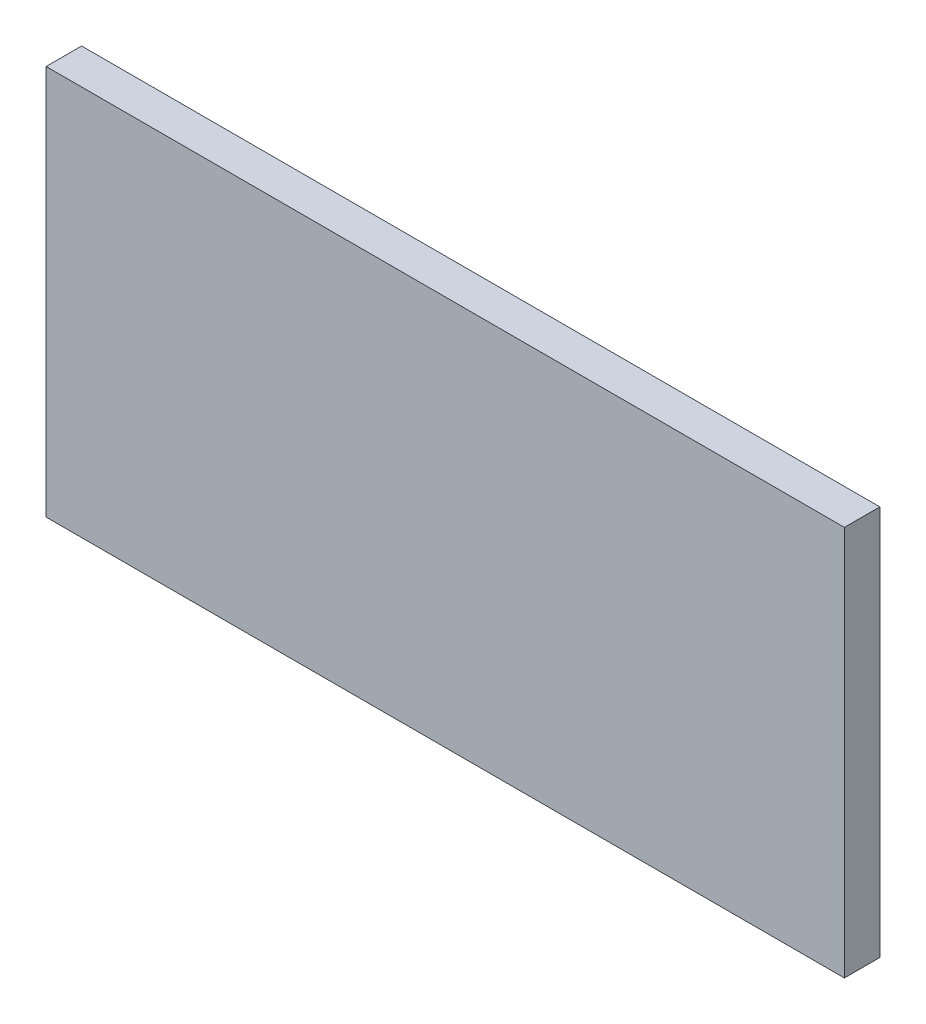
from build123d import *

# Parameters (mm, degrees)
SKETCH_1_W      = 90
SKETCH_1_H      = 44
EXTRUDE_1_DEPTH = 4


with BuildPart() as part:
    # ｽｹｯﾁ1 → ﾎﾞｽ - 押し出し1 (new body)
    with BuildSketch(Plane.XY):
        with Locations((6.702467602, 1.236641221)):
            Rectangle(SKETCH_1_W, SKETCH_1_H)
    extrude(amount=EXTRUDE_1_DEPTH)


solid = part.part
